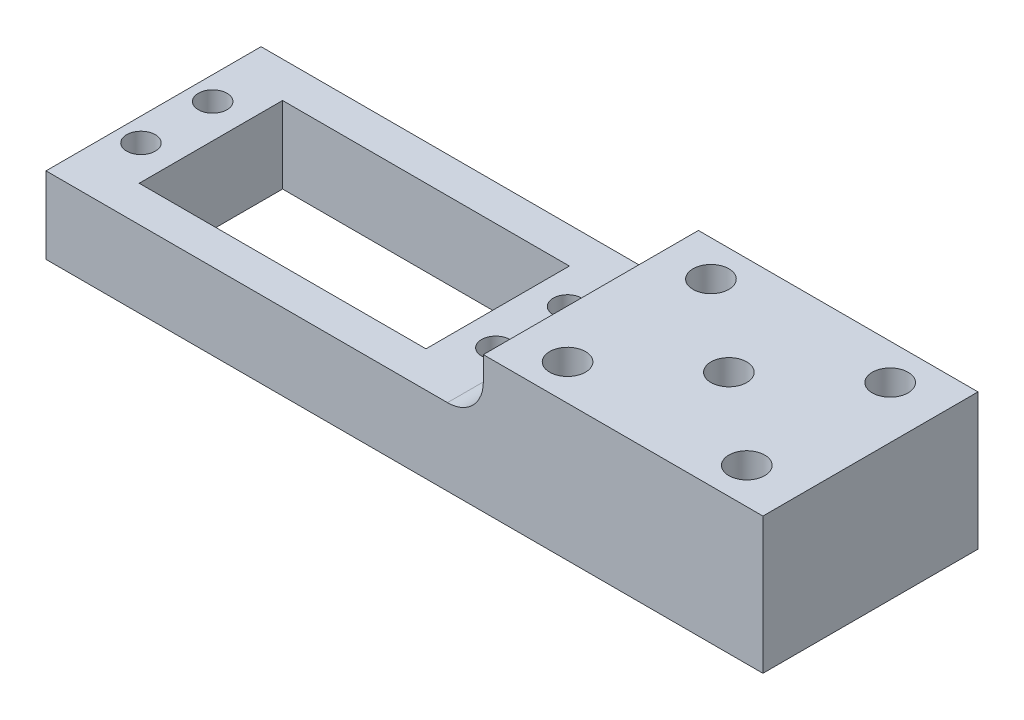
from build123d import *

# Parameters (mm, degrees)
SKETCH1_R           = 2
SKETCH1_W           = 40
SKETCH1_H           = 20
BOSS_EXTRUDE1_DEPTH = 10.7
SKETCH1_4_W         = 39
SKETCH1_4_H         = 30
BOSS_EXTRUDE2_DEPTH = 19
FILLET1_R           = 5
CUT_EXTRUDE2_REACH  = 21
SKETCH2_R           = 2.5


with BuildPart() as part:
    # Sketch1 → Boss-Extrude1 (new body)
    with BuildSketch(Plane(origin=(0, 0, 0), x_dir=(1, 0, 0), z_dir=(0, 1, 0))):
        Polygon((28, 15), (0, 15), (-28, 15), (-28, 0), (-28, -15), (0, -15), (33, -15), (33, 15), align=None)
        with Locations((-24.75, -5)):
            Circle(SKETCH1_R, mode=Mode.SUBTRACT)
        Rectangle(SKETCH1_W, SKETCH1_H, mode=Mode.SUBTRACT)
        with Locations((24.75, -5)):
            Circle(SKETCH1_R, mode=Mode.SUBTRACT)
        with Locations((-24.75, 5)):
            Circle(SKETCH1_R, mode=Mode.SUBTRACT)
        with Locations((24.75, 5)):
            Circle(SKETCH1_R, mode=Mode.SUBTRACT)
    extrude(amount=BOSS_EXTRUDE1_DEPTH)

    # Sketch1_4 → Boss-Extrude2 (add)
    with BuildSketch(Plane(origin=(0, 0, 0), x_dir=(1, 0, 0), z_dir=(0, 1, 0))):
        with Locations((52.5, 0)):
            Rectangle(SKETCH1_4_W, SKETCH1_4_H)
    extrude(amount=BOSS_EXTRUDE2_DEPTH)

    # Fillet1
    fillet1_edges = [part.edges().sort_by_distance(p)[0] for p in [
        (33, 10.7, 0),
    ]]
    fillet(fillet1_edges, radius=FILLET1_R)

    # Sketch2 → Cut-Extrude2 (cut, up to next)
    with BuildSketch(Plane.XZ, mode=Mode.PRIVATE) as cut_extrude2_sk1:
        with Locations((52.25, 0)):
            Circle(SKETCH2_R)
    cut_extrude2_tool1 = extrude(cut_extrude2_sk1.sketch, amount=-CUT_EXTRUDE2_REACH, mode=Mode.PRIVATE) & part.part
    add(cut_extrude2_tool1.solids().sort_by_distance((52.25, 0, 0))[0], mode=Mode.SUBTRACT)
    # Sketch2 → Cut-Extrude2 (cut, up to next)
    with BuildSketch(Plane.XZ, mode=Mode.PRIVATE) as cut_extrude2_sk2:
        with Locations((39.75, 10)):
            Circle(SKETCH2_R)
    cut_extrude2_tool2 = extrude(cut_extrude2_sk2.sketch, amount=-CUT_EXTRUDE2_REACH, mode=Mode.PRIVATE) & part.part
    add(cut_extrude2_tool2.solids().sort_by_distance((39.75, 0, 10))[0], mode=Mode.SUBTRACT)
    # Sketch2 → Cut-Extrude2 (cut, up to next)
    with BuildSketch(Plane.XZ, mode=Mode.PRIVATE) as cut_extrude2_sk3:
        with Locations((39.75, -10)):
            Circle(SKETCH2_R)
    cut_extrude2_tool3 = extrude(cut_extrude2_sk3.sketch, amount=-CUT_EXTRUDE2_REACH, mode=Mode.PRIVATE) & part.part
    add(cut_extrude2_tool3.solids().sort_by_distance((39.75, 0, -10))[0], mode=Mode.SUBTRACT)
    # Sketch2 → Cut-Extrude2 (cut, up to next)
    with BuildSketch(Plane.XZ, mode=Mode.PRIVATE) as cut_extrude2_sk4:
        with Locations((64.75, -10)):
            Circle(SKETCH2_R)
    cut_extrude2_tool4 = extrude(cut_extrude2_sk4.sketch, amount=-CUT_EXTRUDE2_REACH, mode=Mode.PRIVATE) & part.part
    add(cut_extrude2_tool4.solids().sort_by_distance((64.75, 0, -10))[0], mode=Mode.SUBTRACT)
    # Sketch2 → Cut-Extrude2 (cut, up to next)
    with BuildSketch(Plane.XZ, mode=Mode.PRIVATE) as cut_extrude2_sk5:
        with Locations((64.75, 10)):
            Circle(SKETCH2_R)
    cut_extrude2_tool5 = extrude(cut_extrude2_sk5.sketch, amount=-CUT_EXTRUDE2_REACH, mode=Mode.PRIVATE) & part.part
    add(cut_extrude2_tool5.solids().sort_by_distance((64.75, 0, 10))[0], mode=Mode.SUBTRACT)


solid = part.part
